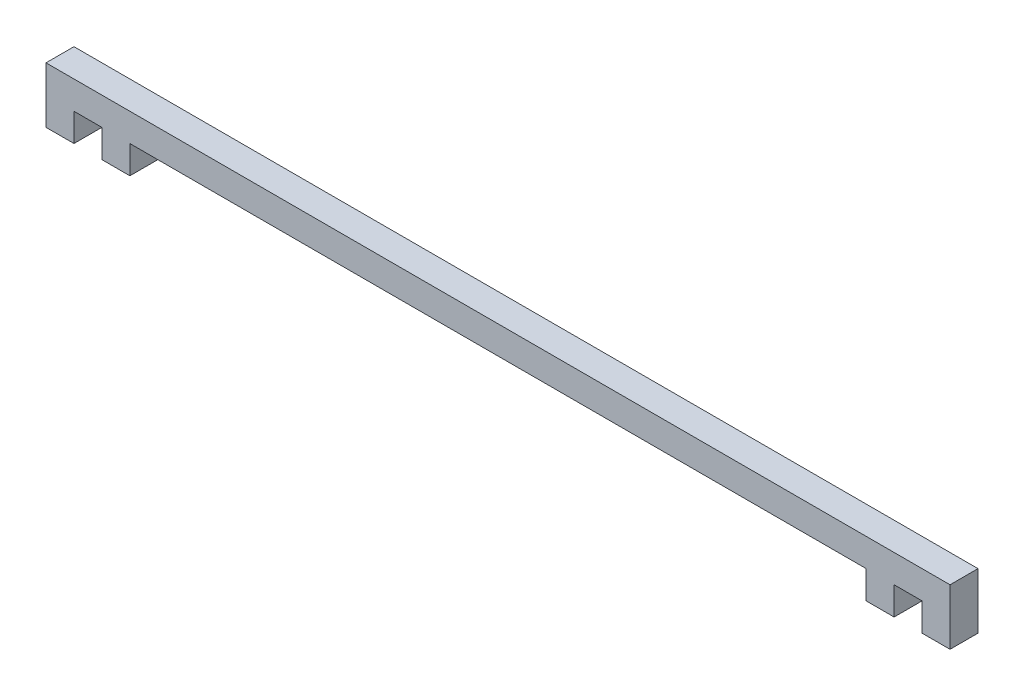
from build123d import *

# Parameters (mm, degrees)
SALIENTE_EXTRUIR1_DEPTH = 3


with BuildPart() as part:
    # Croquis2 → Saliente-Extruir1 (new body)
    with BuildSketch(Plane.XY):
        Polygon((-43.412140575, 0), (35.587859425, 0), (35.587859425, -3), (38.587859425, -3), (38.587859425, 0), (41.587859425, 0), (41.587859425, -3), (44.587859425, -3), (44.587859425, 3), (-52.412140575, 3), (-52.412140575, -3), (-49.412140575, -3), (-49.412140575, 0), (-46.412140575, 0), (-46.412140575, -3), (-43.412140575, -3), align=None)
    extrude(amount=SALIENTE_EXTRUIR1_DEPTH)


solid = part.part
